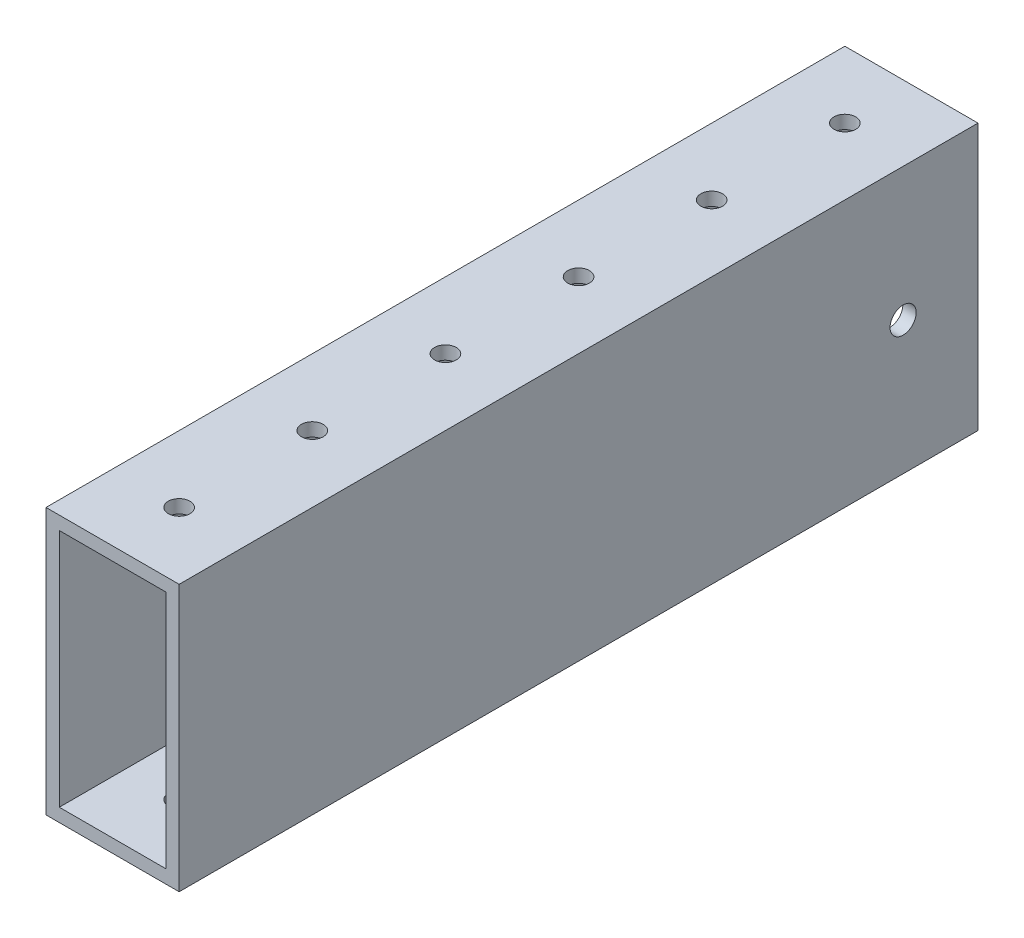
from build123d import *

# Parameters (mm, degrees)
SKETCH1_W           = 25.4
SKETCH1_H           = 50.8
SKETCH1_W_2         = 20.32
SKETCH1_H_2         = 45.72
EXTRUDE_THIN1_DEPTH = 76.2
SKETCH2_R           = 2.0701
CUT_EXTRUDE1_DEPTH  = 51.8
LPATTERN1_COUNT     = 7
LPATTERN1_PITCH     = 25.4
SKETCH3_R           = 2.4892
CUT_EXTRUDE2_DEPTH  = 26.4


with BuildPart() as part:
    # Sketch1 → Extrude-Thin1 (new body, symmetric)
    with BuildSketch(Plane.XY):
        Rectangle(SKETCH1_W, SKETCH1_H)
        Rectangle(SKETCH1_W_2, SKETCH1_H_2, mode=Mode.SUBTRACT)
    extrude(amount=EXTRUDE_THIN1_DEPTH, both=True)

    # Sketch2 → Cut-Extrude1 (cut, through all)
    with BuildSketch(Plane(origin=(0, 25.4, 0), x_dir=(1, 0, 0), z_dir=(0, 1, 0))):
        with Locations((0, -63.5)):
            Circle(SKETCH2_R)
    cut_extrude1 = extrude(amount=-CUT_EXTRUDE1_DEPTH, mode=Mode.SUBTRACT)

    # LPattern1: Cut-Extrude1 ×7
    with Locations(*[(0, 0, -i * LPATTERN1_PITCH) for i in range(1, LPATTERN1_COUNT)]):
        add(cut_extrude1, mode=Mode.SUBTRACT)

    # Sketch3 → Cut-Extrude2 (cut, through all)
    with BuildSketch(Plane(origin=(12.7, 0, 0), x_dir=(0, 0, -1), z_dir=(1, 0, 0))):
        with Locations((61.9125, 0)):
            Circle(SKETCH3_R)
    extrude(amount=-CUT_EXTRUDE2_DEPTH, mode=Mode.SUBTRACT)


solid = part.part
